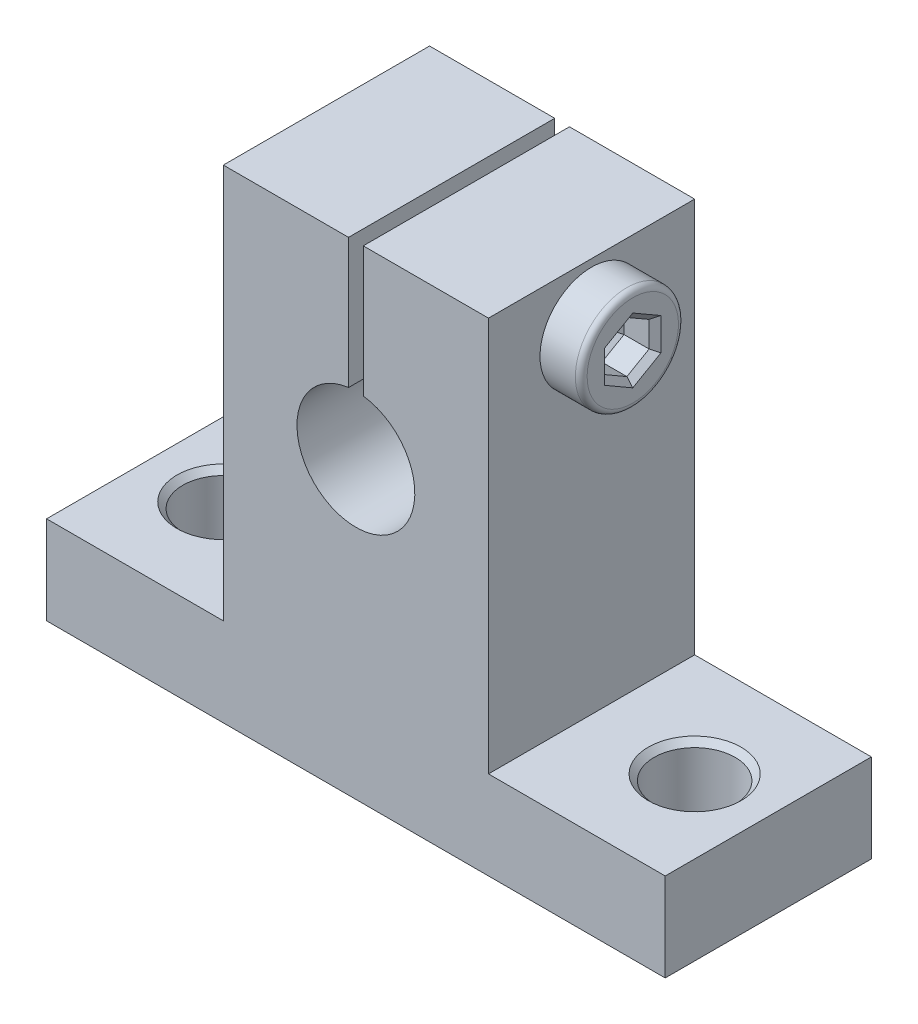
from build123d import *

# Parameters (mm, degrees)
SKETCH1_R                = 4
BOSS_EXTRUDE1_DEPTH      = 14
SKETCH3_W                = 1
SKETCH3_H                = 11.790173319
CUT_EXTRUDE1_DEPTH       = 19
SKETCH2_R                = 2
CUT_EXTRUDE3_DEPTH       = 31
SKETCH5_R                = 2.75
CUT_EXTRUDE5_DEPTH       = 22
TAGLIO_ESTRUSIONE1_DEPTH = 2.5
SMUSSO1_SIZE             = 0.4
RACCORDO1_R              = 0.4
SMUSSO2_SIZE             = 0.4


with BuildPart() as part:
    # Sketch1 → Boss-Extrude1 (new body)
    with BuildSketch(Plane.XY):
        Polygon((-21, 0), (21, 0), (21, 6), (9, 6), (9, 32.8), (-9, 32.8), (-9, 6), (-21, 6), align=None)
        with Locations((0, 20)):
            Circle(SKETCH1_R, mode=Mode.SUBTRACT)
    extrude(amount=BOSS_EXTRUDE1_DEPTH)

    # Sketch3 → Cut-Extrude1 (cut)
    with BuildSketch(Plane.XY.offset(14)):
        with Locations((0, 26.904913341)):
            Rectangle(SKETCH3_W, SKETCH3_H)
    extrude(amount=-CUT_EXTRUDE1_DEPTH, mode=Mode.SUBTRACT)

    # Sketch2 → Cut-Extrude3 (cut)
    with BuildSketch(Plane(origin=(9, 0, 0), x_dir=(0, 0, -1), z_dir=(1, 0, 0))):
        with Locations((-7, 28.8)):
            Circle(SKETCH2_R)
    extrude(amount=-CUT_EXTRUDE3_DEPTH, mode=Mode.SUBTRACT)

    # Sketch5 → Cut-Extrude5 (cut)
    with BuildSketch(Plane(origin=(0, 6, 0), x_dir=(1, 0, 0), z_dir=(0, 1, 0))):
        with Locations((16, -7)):
            Circle(SKETCH5_R)
        with Locations((-16, -7)):
            Circle(SKETCH5_R)
    extrude(amount=-CUT_EXTRUDE5_DEPTH, mode=Mode.SUBTRACT)

    # Smusso2
    smusso2_edges = [part.edges().sort_by_distance(p)[0] for p in [
        (13.25, 6, 7),
        (-18.75, 6, 7),
    ]]
    chamfer(smusso2_edges, length=SMUSSO2_SIZE)


with BuildPart() as body_2:
    # Schizzo1 → Rivoluzione1 (revolve)
    with BuildSketch(Plane.XY.offset(7)):
        Polygon((11.8, 28.8), (-11, 28.8), (-11, 30.4), (-10.6, 30.8), (9, 30.8), (9, 32.3), (11.8, 32.3), align=None)
    revolve(axis=Axis((-22.704724307, 28.8, 7), (1, 0, 0)))

    # Schizzo2 → Taglio-Estrusione1 (cut)
    with BuildSketch(Plane(origin=(11.8, 0, 0), x_dir=(0, 0, -1), z_dir=(1, 0, 0))):
        Polygon((-7, 30.538280632), (-8.505395186, 29.669140316), (-8.505395186, 27.930859684), (-7, 27.061719368), (-5.494604814, 27.930859684), (-5.494604814, 29.669140316), align=None)
    extrude(amount=-TAGLIO_ESTRUSIONE1_DEPTH, mode=Mode.SUBTRACT)

    # Smusso1
    smusso1_edges = [body_2.edges().sort_by_distance(p)[0] for p in [
        (9.3, 30.103710474, 6.247302407),
        (9.3, 28.8, 5.494604814),
        (9.3, 27.496289526, 6.247302407),
        (9.3, 27.496289526, 7.752697593),
        (9.3, 28.8, 8.505395186),
        (9.3, 30.103710474, 7.752697593),
        (11.8, 30.103710474, 6.247302407),
        (11.8, 30.103710474, 7.752697593),
        (11.8, 28.8, 8.505395186),
        (11.8, 27.496289526, 7.752697593),
        (11.8, 27.496289526, 6.247302407),
        (11.8, 28.8, 5.494604814),
    ]]
    chamfer(smusso1_edges, length=SMUSSO1_SIZE)

    # Raccordo1
    raccordo1_edges = [body_2.edges().sort_by_distance(p)[0] for p in [
        (11.8, 25.3, 7),
    ]]
    fillet(raccordo1_edges, radius=RACCORDO1_R)


solid = Compound([part.part, body_2.part])
